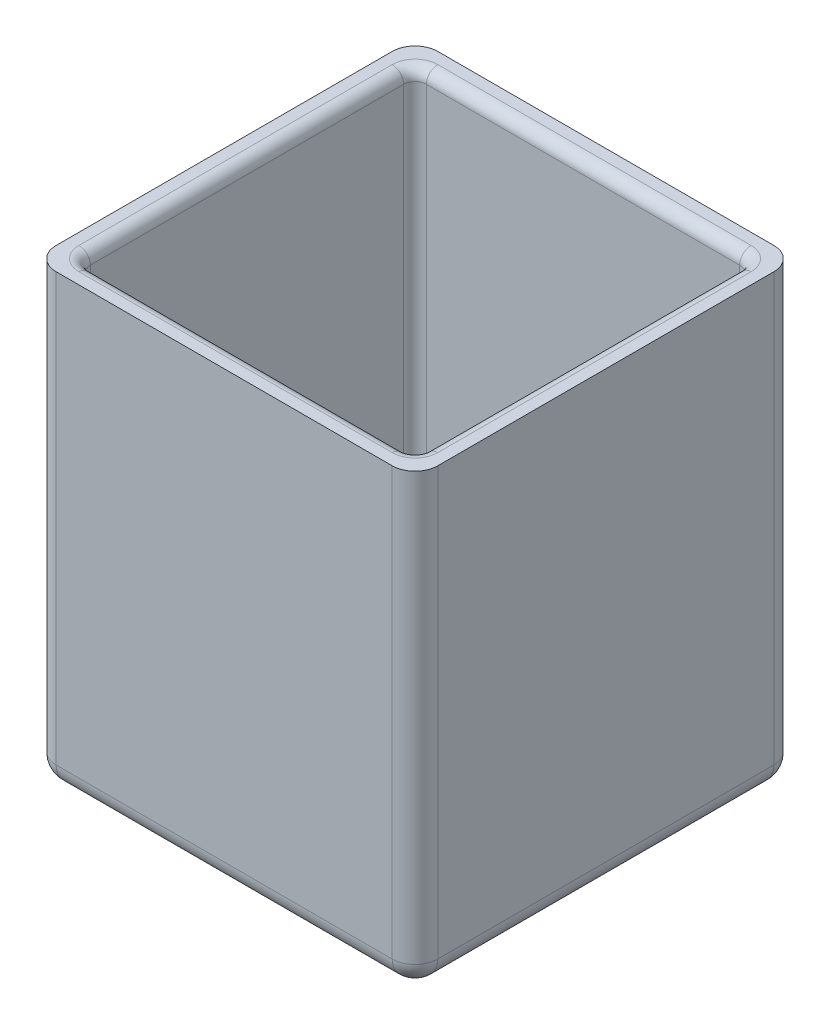
from build123d import *

# Parameters (mm, degrees)
SKETCH1_W           = 33.5
SKETCH1_H           = 33.5
SKETCH1_W_2         = 29.5
SKETCH1_H_2         = 29.5
BOSS_EXTRUDE1_DEPTH = 39.5
SKETCH2_W           = 29.5
SKETCH2_H           = 29.5
BOSS_EXTRUDE2_DEPTH = 3
FILLET_1_R          = 2
FILLET_2_R          = 2
FILLET_3_R          = 1


with BuildPart() as part:
    # Sketch1 → Boss-Extrude1 (new body)
    with BuildSketch(Plane(origin=(0, 0, 0), x_dir=(1, 0, 0), z_dir=(0, 1, 0))):
        with Locations((16.75, 16.75)):
            Rectangle(SKETCH1_W, SKETCH1_H)
        with Locations((16.75, 16.75)):
            Rectangle(SKETCH1_W_2, SKETCH1_H_2, mode=Mode.SUBTRACT)
    extrude(amount=BOSS_EXTRUDE1_DEPTH)

    # Sketch2 → Boss-Extrude2 (add)
    with BuildSketch(Plane.XZ):
        with Locations((16.75, -16.75)):
            Rectangle(SKETCH2_W, SKETCH2_H)
    extrude(amount=-BOSS_EXTRUDE2_DEPTH)

    # Скругление1
    fillet_1_edges = [part.edges().sort_by_distance(p)[0] for p in [
        (0, 19.75, -33.5),
        (33.5, 19.75, -33.5),
        (33.5, 19.75, 0),
        (0, 19.75, 0),
    ]]
    fillet(fillet_1_edges, radius=FILLET_1_R)

    # Скругление2
    fillet_2_edges = [part.edges().sort_by_distance(p)[0] for p in [
        (0, 0, -16.75),
        (16.75, 0, -33.5),
        (33.5, 0, -16.75),
        (16.75, 0, 0),
        (32.914213562, 0, -0.585786438),
        (32.914213562, 0, -32.914213562),
        (0.585786438, 0, -0.585786438),
        (0.585786438, 0, -32.914213562),
    ]]
    fillet(fillet_2_edges, radius=FILLET_2_R)

    # Скругление3
    fillet_3_edges = [part.edges().sort_by_distance(p)[0] for p in [
        (2, 21.25, -31.5),
        (2, 21.25, -2),
        (31.5, 21.25, -2),
        (31.5, 21.25, -31.5),
        (2, 39.5, -16.75),
        (16.75, 39.5, -2),
        (31.5, 39.5, -16.75),
        (16.75, 39.5, -31.5),
        (16.75, 3, -31.5),
        (2, 3, -16.75),
        (16.75, 3, -2),
        (31.5, 3, -16.75),
    ]]
    fillet(fillet_3_edges, radius=FILLET_3_R)


solid = part.part
